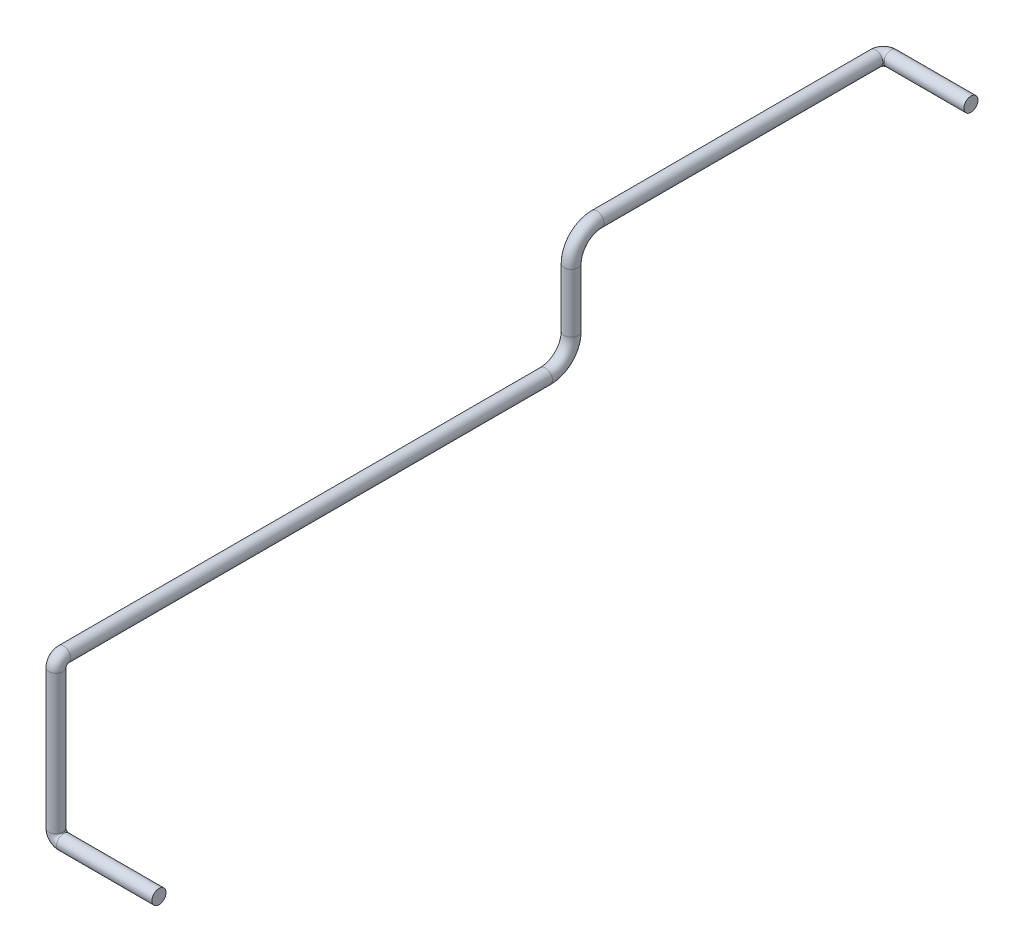
from build123d import *

# Parameters (mm, degrees)
CROQUIS1_R = 13.7


with BuildPart() as part:
    # Barrer1: sweep along a curve in space
    with BuildLine() as barrer1_path:
        Line((0, 0, 0), (-185, 0, 0))
        ThreePointArc((-185, 0, 0), (-195.606601718, 4.393398282, 0), (-200, 15, 0))
        Line((-200, 15, 0), (-200, 285, 0))
        ThreePointArc((-200, 300, -15), (-200, 295.606601718, -4.393398282), (-200, 285, 0))
        Line((-200, 300, -15), (-200, 300, -950))
        ThreePointArc((-200, 350, -1000), (-200, 314.644660941, -985.355339059), (-200, 300, -950))
        Line((-200, 464, -1000), (-200, 350, -1000))
        ThreePointArc((-200, 464, -1000), (-200, 499.355339059, -1014.644660941), (-200, 514, -1050))
        Line((-200, 514, -1050), (-200, 514, -1591))
        ThreePointArc((-200, 514, -1591), (-195.606601718, 514, -1601.606601718), (-185, 514, -1606))
        Line((-185, 514, -1606), (-30, 514, -1606))
    # Croquis1 → Barrer1 (sweep)
    with BuildSketch(Plane(origin=(0, 0, 0), x_dir=(0, 0, -1), z_dir=(1, 0, 0))):
        Circle(CROQUIS1_R)
    sweep(path=barrer1_path.line)


solid = part.part
